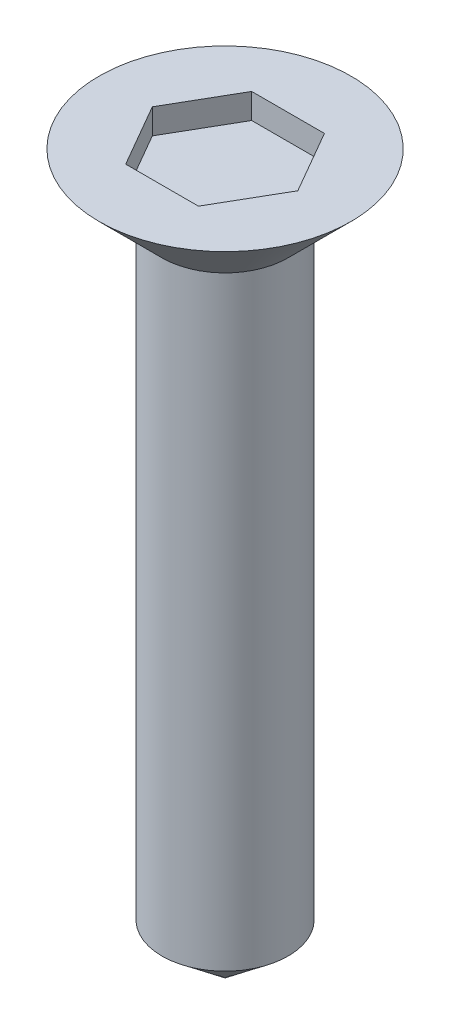
from build123d import *

# Parameters (mm, degrees)
CROQUIS1_R              = 1.25
SALIENTE_EXTRUIR1_DEPTH = 12
CORTAR_EXTRUIR1_DEPTH   = 0.5


with BuildPart() as part:
    # Croquis1 → Saliente-Extruir1 (new body)
    with BuildSketch(Plane(origin=(0, 0, 0), x_dir=(1, 0, 0), z_dir=(0, 1, 0))):
        Circle(CROQUIS1_R)
    extrude(amount=SALIENTE_EXTRUIR1_DEPTH)

    # Croquis2 one side → Revolución1 (revolve)
    with BuildSketch(Plane(origin=(0, 0, 0), x_dir=(0, 0, -1), z_dir=(1, 0, 0))):
        Polygon((0, 13.25), (0, 12), (1.25, 12), (2.5, 13.25), align=None)
    revolve(axis=Axis((0, 13.25, 0), (0, -1, 0)))

    # Croquis3 → Cortar-Extruir1 (cut)
    with BuildSketch(Plane(origin=(0, 13.25, 0), x_dir=(1, 0, 0), z_dir=(0, 1, 0))):
        Polygon((1.443375673, 0), (0.721687836, 1.25), (-0.721687836, 1.25), (-1.443375673, 0), (-0.721687836, -1.25), (0.721687836, -1.25), align=None)
    extrude(amount=-CORTAR_EXTRUIR1_DEPTH, mode=Mode.SUBTRACT)

    # Croquis4 one side → Revolución2 (revolve)
    with BuildSketch(Plane.XY):
        Polygon((0, 0), (0, -1), (1.25, 0), align=None)
    revolve(axis=Axis((0, 0, 0), (0, -1, 0)))


solid = part.part
